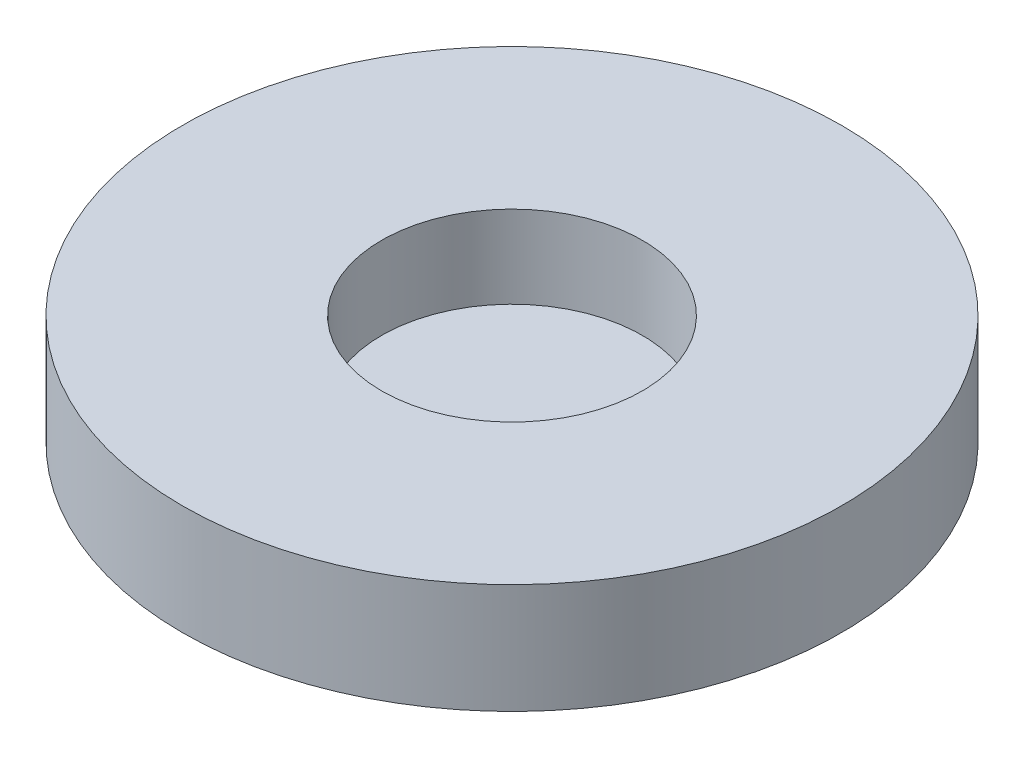
from build123d import *

# Parameters (mm, degrees)
SKETCH1_R           = 38.1
BOSS_EXTRUDE1_DEPTH = 12.7
SKETCH2_R           = 15.08125
CUT_EXTRUDE1_DEPTH  = 9.525


with BuildPart() as part:
    # Sketch1 → Boss-Extrude1 (new body)
    with BuildSketch(Plane(origin=(0, 0, 0), x_dir=(1, 0, 0), z_dir=(0, 1, 0))):
        Circle(SKETCH1_R)
    extrude(amount=BOSS_EXTRUDE1_DEPTH)

    # Sketch2 → Cut-Extrude1 (cut)
    with BuildSketch(Plane(origin=(0, 12.7, 0), x_dir=(1, 0, 0), z_dir=(0, 1, 0))):
        Circle(SKETCH2_R)
    extrude(amount=-CUT_EXTRUDE1_DEPTH, mode=Mode.SUBTRACT)


solid = part.part
